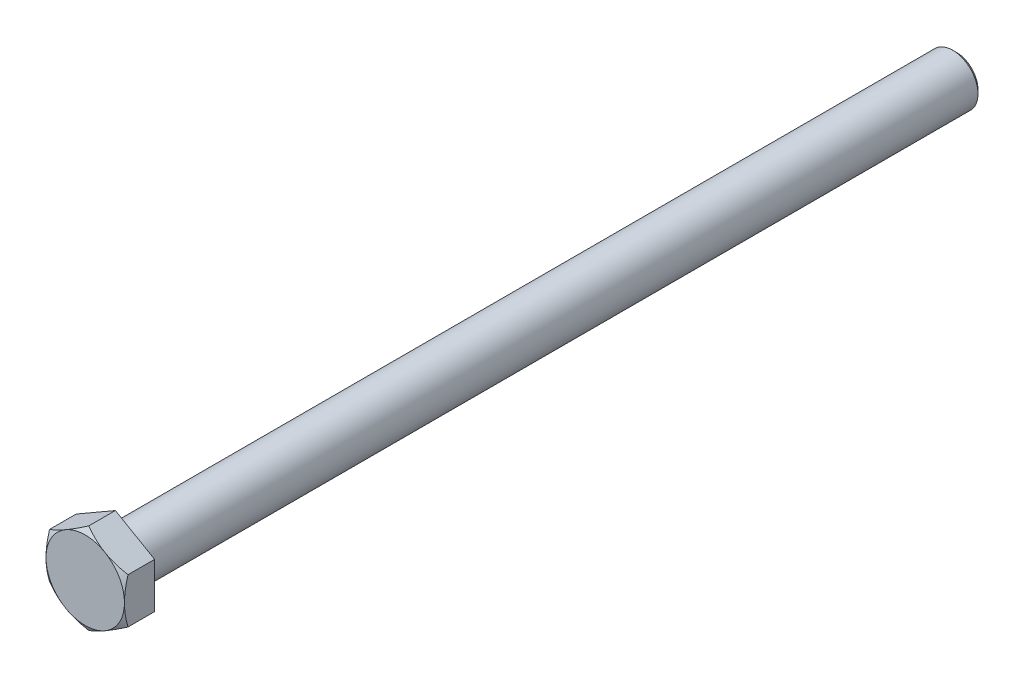
from build123d import *

# Parameters (mm, degrees)
BOSS_EXTRUDE1_DEPTH = 7.32


with BuildPart() as part:
    # Sketch1 → Boss-Extrude1 (new body)
    with BuildSketch(Plane.XY):
        Polygon((0, 10.779129526), (-9.335, 5.389564763), (-9.335, -5.389564763), (0, -10.779129526), (9.335, -5.389564763), (9.335, 5.389564763), align=None)
    extrude(amount=BOSS_EXTRUDE1_DEPTH)

    # Sketch2 → Revolve1 (revolve)
    with BuildSketch(Plane(origin=(0, 0, 0), x_dir=(0, 0, -1), z_dir=(1, 0, 0))):
        with BuildLine():
            Line((0, 0), (0, 6.6))
            ThreePointArc((0, 6.6), (0.175735931, 6.175735931), (0.6, 6))
            Line((0.6, 6), (199.1, 6))
            Line((199.1, 6), (200, 5.1))
            Line((200, 5.1), (200, 0))
            Line((200, 0), (0, 0))
        make_face()
    revolve(axis=Axis((0, 0, 0), (0, 0, -1)))

    # Sketch3 → Cut-Revolve1 (revolve, cut)
    with BuildSketch(Plane(origin=(0, 0, 0), x_dir=(0, 0, -1), z_dir=(1, 0, 0))):
        Polygon((-7.32, 10.779129526), (-6.48623143, 10.779129526), (-7.32, 9.335), align=None)
        Polygon((-0.15, 10.779129526), (-0.15, 8.78660254), (0, 8.7), (0, 10.779129526), align=None)
    revolve(axis=Axis((0, 0, 12.204941078), (0, 0, -1)), mode=Mode.SUBTRACT)


solid = part.part
